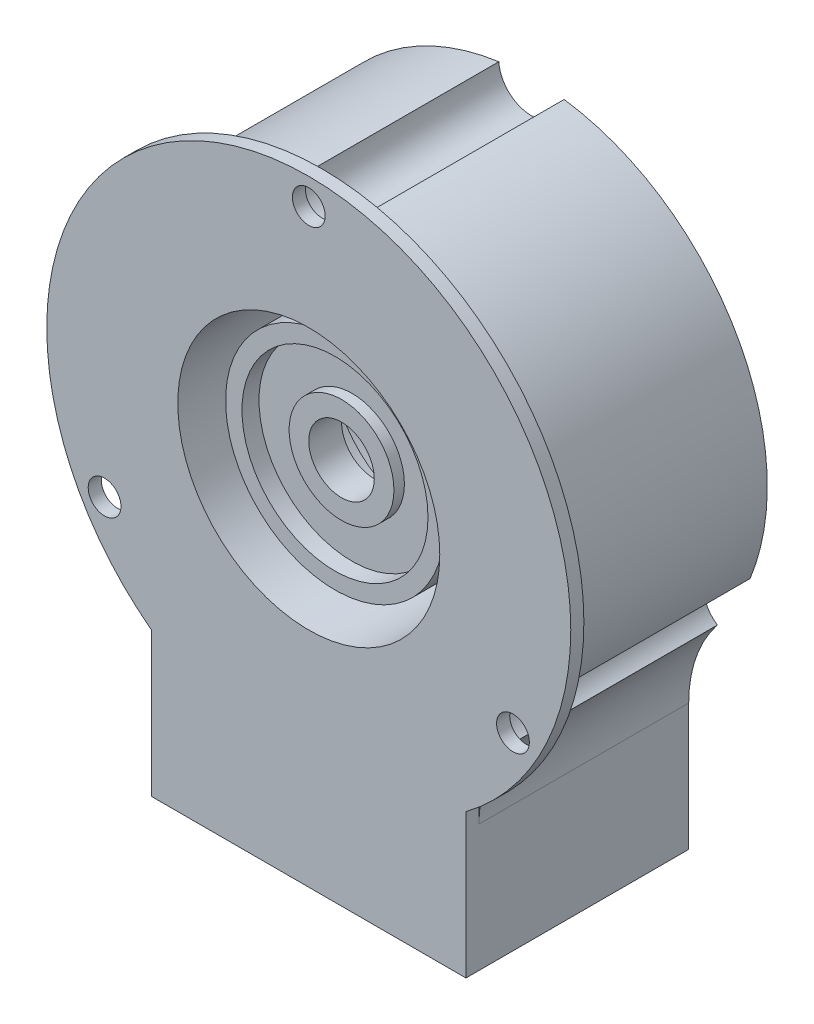
from build123d import *

# Parameters (mm, degrees)
EXTRUDE1_DEPTH                   = 16
EXTRUDE2_DEPTH                   = 1
CBORE_FOR_M2_5_SHCS1_D           = 2.5
CBORE_FOR_M2_5_SHCS1_CBORE_D     = 5
CBORE_FOR_M2_5_SHCS1_CBORE_DEPTH = 16
SKETCH6_R                        = 10
CUT_EXTRUDE1_DEPTH               = 15


with BuildPart() as part:
    # Sketch1 → Extrude1 (new body)
    with BuildSketch(Plane.XY):
        with BuildLine():
            Line((-12, 0), (12, 0))
            Line((12, 0), (12, 9.679491924))
            ThreePointArc((12, 9.679491924), (12.550888175, 12.952760278), (14.142857143, 15.865387666))
            ThreePointArc((14.142857143, 15.865387666), (0, 45), (-14.142857143, 15.865387666))
            ThreePointArc((-14.142857143, 15.865387666), (-12.550888175, 12.952760278), (-12, 9.679491924))
            Line((-12, 9.679491924), (-12, 0))
        make_face()
    extrude(amount=EXTRUDE1_DEPTH)

    # Sketch2 → Extrude2 (add)
    with BuildSketch(Plane.XY.offset(16)):
        with BuildLine():
            Line((12, 11), (12, 0))
            Line((12, 0), (-12, 0))
            Line((-12, 0), (-12, 11))
            ThreePointArc((-12, 11), (0, 47), (12, 11))
        make_face()
    extrude(amount=EXTRUDE2_DEPTH)

    # CBORE for M2.5 SHCS1 (through all)
    with Locations(Plane(origin=(0, 0, 0), x_dir=(-1, 0, 0), z_dir=(0, 0, -1))):
        with Locations((0, 45), (15.588457268, 18), (-15.588457268, 18)):
            CounterBoreHole(CBORE_FOR_M2_5_SHCS1_D / 2, CBORE_FOR_M2_5_SHCS1_CBORE_D / 2, CBORE_FOR_M2_5_SHCS1_CBORE_DEPTH)

    # Sketch6 → Cut-Extrude1 (cut)
    with BuildSketch(Plane.XY.offset(17)):
        with Locations((0, 27)):
            Circle(SKETCH6_R)
    extrude(amount=-CUT_EXTRUDE1_DEPTH, mode=Mode.SUBTRACT)


with BuildPart() as body_2:
    # Sketch7 → Revolve1 (revolve)
    with BuildSketch(Plane(origin=(0, 0, 0), x_dir=(0, 0, -1), z_dir=(1, 0, 0))):
        Polygon((-8, 34.35), (-8, 35.35), (-15, 35.35), (-15, 34.1), (-13.7, 34.1), (-13.7, 31), (-14.5, 31), (-14.5, 29.5), (-12, 29.5), (-12, 34.35), align=None)
    revolve(axis=Axis((0, 27, 16), (0, 0, -1)))


solid = Compound([part.part, body_2.part])
